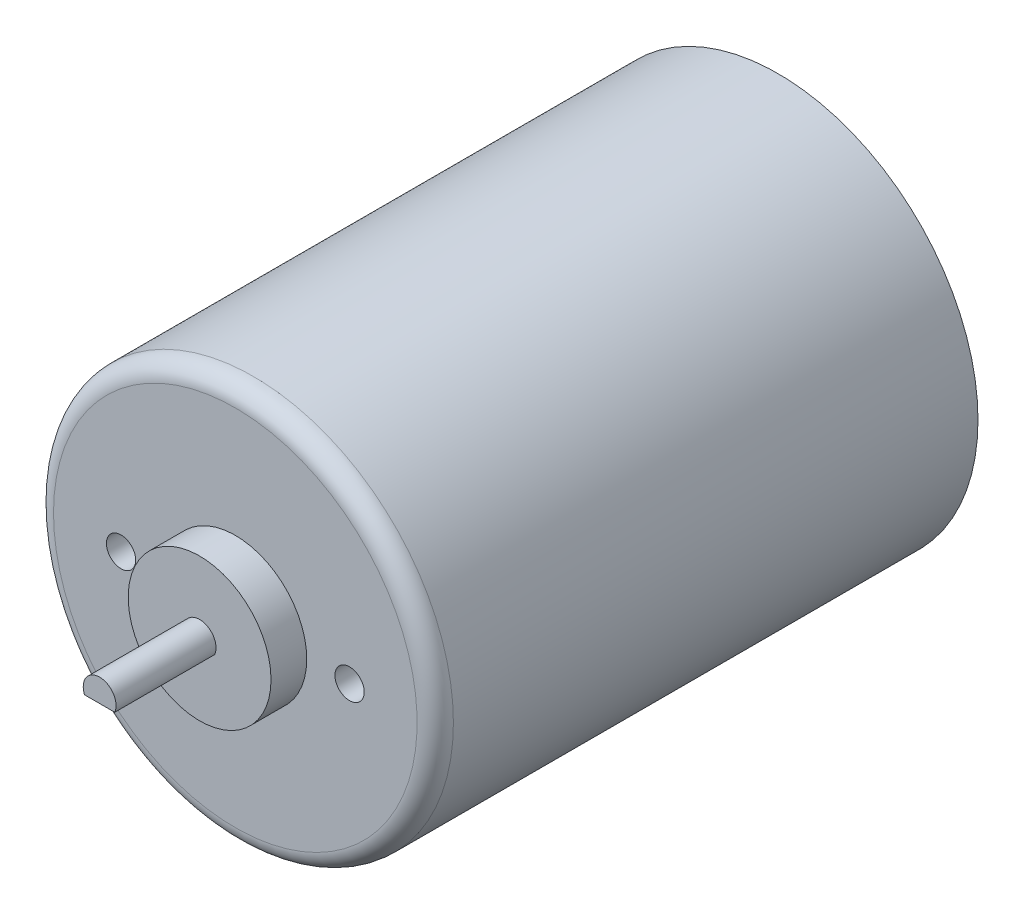
from build123d import *

# Parameters (mm, degrees)
BOSS_EXTRUDE1_DEPTH          = 7
M2_5X0_45_TAPPED_HOLE1_D     = 2.05
M2_5X0_45_TAPPED_HOLE1_DEPTH = 6.4262
M2_5X0_45_TAPPED_HOLE1_TIP   = 0.615882135
FILLET1_R                    = 1.27


with BuildPart() as part:
    # Sketch1 → Revolve1 (revolve)
    with BuildSketch(Plane(origin=(0, 0, 0), x_dir=(0, 0, -1), z_dir=(1, 0, 0))):
        Polygon((-2.5, 0), (-2.5, 5), (0, 5), (0, 14), (38, 14), (38, 0), align=None)
    revolve(axis=Axis((0, 0, 0), (0, 0, -1)))

    # Sketch2 → Boss-Extrude1 (add)
    with BuildSketch(Plane.XY.offset(2.5)):
        with BuildLine():
            Line((-1.058300524, -0.45), (1.058300524, -0.45))
            ThreePointArc((1.058300524, -0.45), (0, 1.15), (-1.058300524, -0.45))
        make_face()
    extrude(amount=BOSS_EXTRUDE1_DEPTH)

    # M2.5x0.45 Tapped Hole1
    with Locations(Plane.XY):
        with Locations((8, 0), (-8, 0)):
            Hole(M2_5X0_45_TAPPED_HOLE1_D / 2, depth=M2_5X0_45_TAPPED_HOLE1_DEPTH)
            with Locations((0, 0, -(M2_5X0_45_TAPPED_HOLE1_DEPTH + M2_5X0_45_TAPPED_HOLE1_TIP / 2))):  # 118° drill point
                Cone(0, M2_5X0_45_TAPPED_HOLE1_D / 2, M2_5X0_45_TAPPED_HOLE1_TIP, mode=Mode.SUBTRACT)

    # Fillet1
    fillet1_edges = [part.edges().sort_by_distance(p)[0] for p in [
        (0, -14, 0),
    ]]
    fillet(fillet1_edges, radius=FILLET1_R)


solid = part.part
